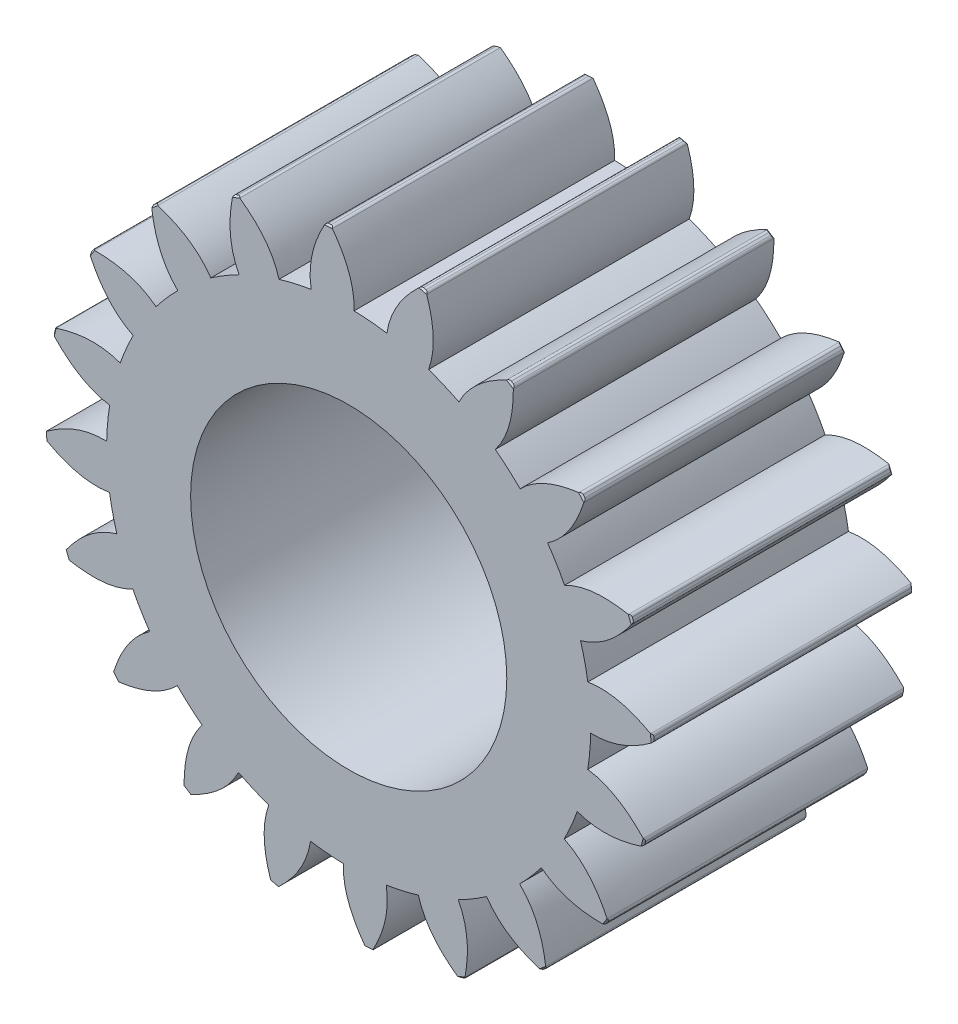
from build123d import *

# Parameters (mm, degrees)
BOSS_EXTRUDE1_DEPTH          = 32.97
CHAMFER1_SIZE                = 0.2
FILLET1_R                    = 0.4
CIRPATTERN1_COUNT            = 20
CHAMFER1_OF_CIRPATTERN1_SIZE = 0.2
FILLET1_OF_CIRPATTERN1_R     = 0.4
SKETCH2_R                    = 20
CUT_EXTRUDE1_DEPTH           = 33.9700001


with BuildPart() as part:
    # Sketch1 → Boss-Extrude1 (new body)
    with BuildSketch(Plane.XY):
        with BuildLine():
            add(Edge.make_bspline(
                [(-4.88219696, 32.004761799), (-4.873405166, 32.634313242), (-4.628092684, 34.861978531), (-3.744666809, 36.962740281), (-2.948696062, 38.386914327)],
                knots=[0, 0, 0, 0, 0.062703975, 0.224889057, 0.224889057, 0.224889057, 0.224889057], degree=3))
            add(Edge.make_bspline(
                [(-4.748626428, 30.254605799), (-4.848288617, 30.844328658), (-4.890250395, 31.428081883), (-4.88219696, 32.004761799)],
                knots=[-0.057437916, -0.057437916, -0.057437916, -0.057437916, 0, 0, 0, 0], degree=3))
            ThreePointArc((-4.748626428, 30.254605799), (2.041965747, -30.556848674), (0.680843939, 30.617430926))
            add(Edge.make_bspline(
                [(0.680843939, 30.617430926), (0.723325625, 31.867713308), (0.243359268, 34.666045644), (-1.206747249, 37.132337115), (-2.185135683, 38.437939357)],
                knots=[-0.057437916, -0.057437916, -0.057437916, -0.057437916, 0.062703975, 0.224889057, 0.224889057, 0.224889057, 0.224889057], degree=3))
            ThreePointArc((-2.185135683, 38.437939357), (-2.567042654, 38.414324047), (-2.948696062, 38.386914327))
        make_face()
    boss_extrude1 = extrude(amount=BOSS_EXTRUDE1_DEPTH)

    # Chamfer1
    chamfer1_edges = [part.edges().sort_by_distance(p)[0] for p in [
        (-2.567042654, 38.414324047, 32.97),
        (-2.567042654, 38.414324047, 0),
    ]]
    chamfer(chamfer1_edges, length=CHAMFER1_SIZE)

    # Fillet1
    fillet1_edges = [part.edges().sort_by_distance(p)[0] for p in [
        (-2.185135683, 38.437939357, 16.485),
        (-2.948696062, 38.386914327, 16.485),
    ]]
    fillet(fillet1_edges, radius=FILLET1_R)

    # CirPattern1: Boss-Extrude1 ×20 about axis
    cirpattern1_axis = Axis((0, 0, 0), (0, 0, -1))
    for i in range(1, CIRPATTERN1_COUNT):
        add(boss_extrude1.rotate(cirpattern1_axis, i * 360 / CIRPATTERN1_COUNT))

    # Chamfer1 of CirPattern1
    chamfer1_of_cirpattern1_edges = [part.edges().sort_by_distance(p)[0] for p in [
        (9.429276315, 37.32745301, 32.97),
        (9.429276315, 37.32745301, 0),
        (20.50259202, 32.586710796, 32.97),
        (20.50259202, 32.586710796, 0),
        (29.568971168, 24.656154284, 32.97),
        (29.568971168, 24.656154284, 0),
        (35.740933399, 14.312081601, 32.97),
        (35.740933399, 14.312081601, 0),
        (38.414324047, 2.567042654, 32.97),
        (38.414324047, 2.567042654, 0),
        (37.32745301, -9.429276315, 32.97),
        (37.32745301, -9.429276315, 0),
        (32.586710796, -20.50259202, 32.97),
        (32.586710796, -20.50259202, 0),
        (24.656154284, -29.568971168, 32.97),
        (24.656154284, -29.568971168, 0),
        (14.312081601, -35.740933399, 32.97),
        (14.312081601, -35.740933399, 0),
        (2.567042654, -38.414324047, 32.97),
        (2.567042654, -38.414324047, 0),
        (-9.429276315, -37.32745301, 32.97),
        (-9.429276315, -37.32745301, 0),
        (-20.50259202, -32.586710796, 32.97),
        (-20.50259202, -32.586710796, 0),
        (-29.568971168, -24.656154284, 32.97),
        (-29.568971168, -24.656154284, 0),
        (-35.740933399, -14.312081601, 32.97),
        (-35.740933399, -14.312081601, 0),
        (-38.414324047, -2.567042654, 32.97),
        (-38.414324047, -2.567042654, 0),
        (-37.32745301, 9.429276315, 32.97),
        (-37.32745301, 9.429276315, 0),
        (-32.586710796, 20.50259202, 32.97),
        (-32.586710796, 20.50259202, 0),
        (-24.656154284, 29.568971168, 32.97),
        (-24.656154284, 29.568971168, 0),
        (-14.312081601, 35.740933399, 32.97),
        (-14.312081601, 35.740933399, 0),
    ]]
    chamfer(chamfer1_of_cirpattern1_edges, length=CHAMFER1_OF_CIRPATTERN1_SIZE)

    # Fillet1 of CirPattern1
    fillet1_of_cirpattern1_edges = [part.edges().sort_by_distance(p)[0] for p in [
        (9.79978896, 37.23189676, 16.485),
        (9.057832284, 37.419322205, 16.485),
        (20.82544198, 32.381336698, 16.485),
        (20.177716897, 32.788866111, 16.485),
        (29.81255564, 24.361065785, 16.485),
        (29.322465993, 24.948807348, 16.485),
        (35.881408638, 13.95616402, 16.485),
        (35.596927816, 14.666585493, 16.485),
        (38.437939357, 2.185135683, 16.485),
        (38.386914327, 2.948696062, 16.485),
        (37.23189676, -9.79978896, 16.485),
        (37.419322205, -9.057832284, 16.485),
        (32.381336698, -20.82544198, 16.485),
        (32.788866111, -20.177716897, 16.485),
        (24.361065785, -29.81255564, 16.485),
        (24.948807348, -29.322465993, 16.485),
        (13.95616402, -35.881408638, 16.485),
        (14.666585493, -35.596927816, 16.485),
        (2.185135683, -38.437939357, 16.485),
        (2.948696062, -38.386914327, 16.485),
        (-9.79978896, -37.23189676, 16.485),
        (-9.057832284, -37.419322205, 16.485),
        (-20.82544198, -32.381336698, 16.485),
        (-20.177716897, -32.788866111, 16.485),
        (-29.81255564, -24.361065785, 16.485),
        (-29.322465993, -24.948807348, 16.485),
        (-35.881408638, -13.95616402, 16.485),
        (-35.596927816, -14.666585493, 16.485),
        (-38.437939357, -2.185135683, 16.485),
        (-38.386914327, -2.948696062, 16.485),
        (-37.23189676, 9.79978896, 16.485),
        (-37.419322205, 9.057832284, 16.485),
        (-32.381336698, 20.82544198, 16.485),
        (-32.788866111, 20.177716897, 16.485),
        (-24.361065785, 29.81255564, 16.485),
        (-24.948807348, 29.322465993, 16.485),
        (-13.95616402, 35.881408638, 16.485),
        (-14.666585493, 35.596927816, 16.485),
    ]]
    fillet(fillet1_of_cirpattern1_edges, radius=FILLET1_OF_CIRPATTERN1_R)

    # Sketch2 → Cut-Extrude1 (cut, through all)
    with BuildSketch(Plane(origin=(0, 0, 0), x_dir=(-1, 0, 0), z_dir=(0, 0, -1))):
        Circle(SKETCH2_R)
    extrude(amount=-CUT_EXTRUDE1_DEPTH, mode=Mode.SUBTRACT)


solid = part.part
